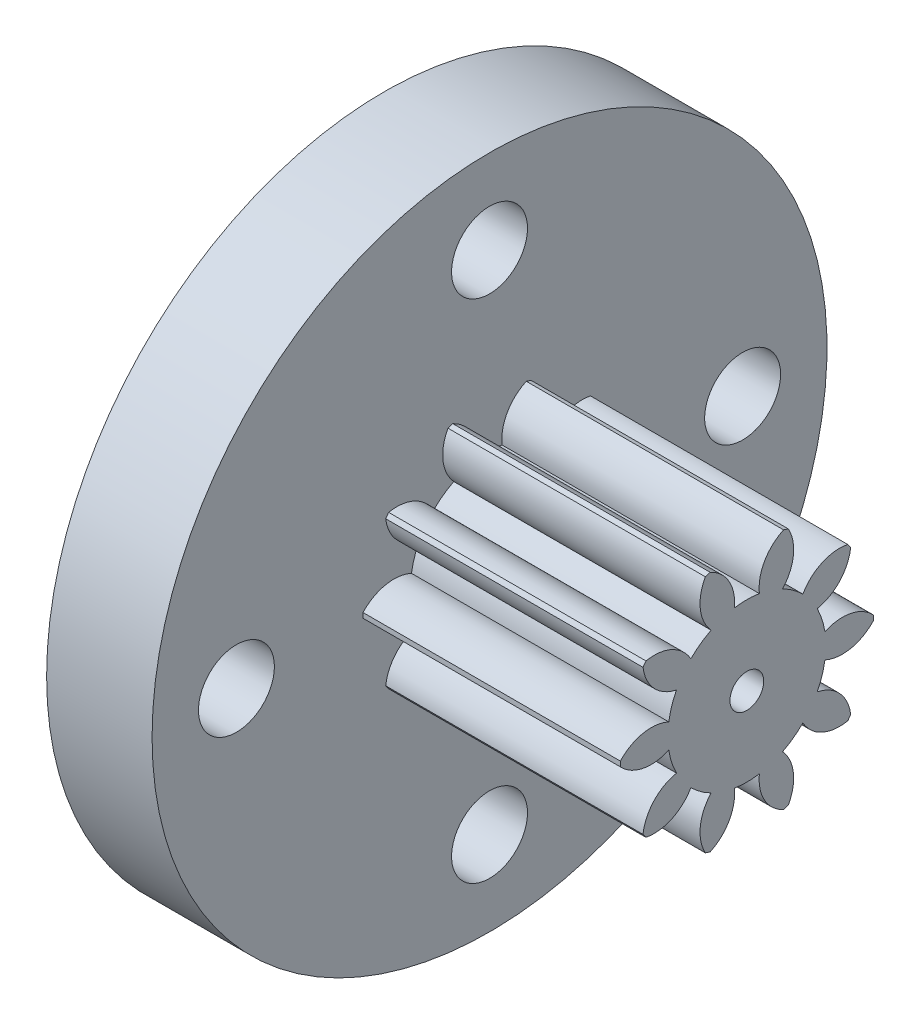
from build123d import *

# Parameters (mm, degrees)
BASPROSKE_W                = 8.6
BASPROSKE_H                = 3
TOOTHCUT_DEPTH             = 10.589577676
TEETHCUTS_COUNT            = 10
BORSKE_R                   = 0.4
BORE_DEPTH                 = 50.0000508
SKETCH1_R                  = 8
BOSS_EXTRUDE1_DEPTH        = 2.5
M1_6_CLEARANCE_HOLE1_D     = 1.8
M1_6_CLEARANCE_HOLE1_DEPTH = 4.25
M1_6_CLEARANCE_HOLE1_TIP   = 0.540774557


with BuildPart() as part:
    # BasProSke → Base-Revolve (revolve)
    with BuildSketch(Plane(origin=(0, 0, 0), x_dir=(1, 0, 0), z_dir=(0, 1, 0)), mode=Mode.PRIVATE) as base_revolve_sk:
        with Locations((4.3, 1.5)):
            Rectangle(BASPROSKE_W, BASPROSKE_H)
    revolve(base_revolve_sk.sketch.rotate(Axis((-10, 0, 0), (1, 0, 0)), 180), axis=Axis((-10, 0, 0), (1, 0, 0)))

    # TooCutSke → ToothCut (cut, through all)
    with BuildSketch(Plane(origin=(0, 0, 0), x_dir=(0, 0, -1), z_dir=(1, 0, 0))):
        with BuildLine():
            ThreePointArc((0.296449938, 1.850403587), (0, 1.874), (-0.296449938, 1.850403587))
            ThreePointArc((-0.296449938, 1.850403587), (-0.428089565, 2.470295585), (-0.905889751, 2.886591228))
            ThreePointArc((-0.905889751, 2.886591228), (0, 3.0254), (0.905889751, 2.886591228))
            ThreePointArc((0.905889751, 2.886591228), (0.428089565, 2.470295585), (0.296449938, 1.850403587))
        make_face()
    toothcut = extrude(amount=TOOTHCUT_DEPTH, mode=Mode.SUBTRACT)

    # TeethCuts: ToothCut ×10 about axis
    teethcuts_axis = Axis((0, 0, 0), (1, 0, 0))
    for i in range(1, TEETHCUTS_COUNT):
        add(toothcut.rotate(teethcuts_axis, i * 360 / TEETHCUTS_COUNT), mode=Mode.SUBTRACT)

    # BorSke → Bore (cut, symmetric)
    with BuildSketch(Plane(origin=(0, 0, 0), x_dir=(0, 0, -1), z_dir=(1, 0, 0))):
        with Locations(Location((0, 0, 0), (0, 0, 180))):
            Circle(BORSKE_R)
    extrude(amount=BORE_DEPTH, both=True, mode=Mode.SUBTRACT)

    # Sketch1 → Boss-Extrude1 (add)
    with BuildSketch(Plane.ZY):
        Circle(SKETCH1_R)
    extrude(amount=-BOSS_EXTRUDE1_DEPTH)

    # M1.6 Clearance Hole1
    with Locations(Plane(origin=(2.5, 0, 0), x_dir=(0, 0, -1), z_dir=(1, 0, 0))):
        with Locations((0, 6), (6, 0), (0, -6), (-6, 0)):
            Hole(M1_6_CLEARANCE_HOLE1_D / 2, depth=M1_6_CLEARANCE_HOLE1_DEPTH)
            with Locations((0, 0, -(M1_6_CLEARANCE_HOLE1_DEPTH + M1_6_CLEARANCE_HOLE1_TIP / 2))):  # 118° drill point
                Cone(0, M1_6_CLEARANCE_HOLE1_D / 2, M1_6_CLEARANCE_HOLE1_TIP, mode=Mode.SUBTRACT)


solid = part.part
